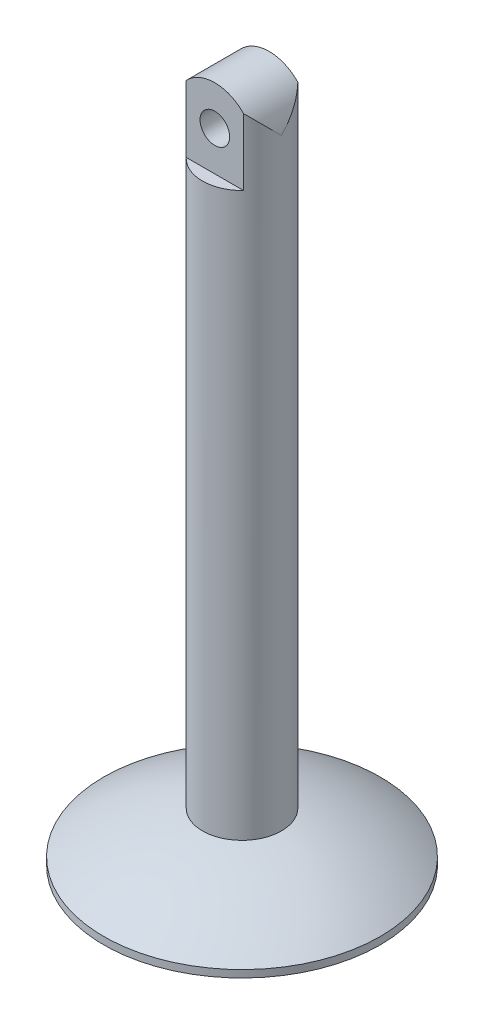
from build123d import *

# Parameters (mm, degrees)
SKETCH1_W               = 4
SKETCH1_H               = 65
CUT_EXTRUDE2_DEPTH      = 15.0000001
CUT_EXTRUDE2_DEPTH_BACK = 15.0000001
SKETCH3_W               = 1.25
SKETCH3_H               = 8
CUT_EXTRUDE3_DEPTH      = 15.0000001
CUT_EXTRUDE3_DEPTH_BACK = 15.0000001


with BuildPart() as part:
    # Sketch1 → Revolve1 (revolve)
    with BuildSketch(Plane.XY):
        with BuildLine():
            ThreePointArc((-4, -65), (-9.225090437, -66.601484736), (-14, -69.259785338))
            Line((-14, -69.259785338), (-14, -70))
            Line((-14, -70), (0, -70))
            Line((0, -70), (0, -65))
            Line((0, -65), (-4, -65))
        make_face()
        with Locations((-2, -32.5)):
            Rectangle(SKETCH1_W, SKETCH1_H)
    revolve(axis=Axis((0, 0, 0), (0, -1, 0)))

    # Sketch2 → Cut-Extrude2 (cut, two sides)
    with BuildSketch(Plane.XY) as cut_extrude2_sk:
        with BuildLine():
            Line((-4, 0), (-4, -4))
            ThreePointArc((-4, -4), (-2.828427125, -1.171572875), (0, 0))
            Line((0, 0), (-4, 0))
        make_face()
        with BuildLine():
            ThreePointArc((0, 0), (2.828427125, -1.171572875), (4, -4))
            Line((4, -4), (4, 0))
            Line((4, 0), (0, 0))
        make_face()
        with BuildLine():
            ThreePointArc((-1.5, -4), (0, -5.5), (1.5, -4))
            Line((1.5, -4), (-1.5, -4))
        make_face()
        with BuildLine():
            Line((-1.5, -4), (1.5, -4))
            ThreePointArc((1.5, -4), (0, -2.5), (-1.5, -4))
        make_face()
    extrude(amount=CUT_EXTRUDE2_DEPTH, mode=Mode.SUBTRACT)
    extrude(cut_extrude2_sk.sketch, amount=-CUT_EXTRUDE2_DEPTH_BACK, mode=Mode.SUBTRACT)

    # Sketch3 → Cut-Extrude3 (cut, two sides)
    with BuildSketch(Plane(origin=(0, 0, 0), x_dir=(0, 0, -1), z_dir=(1, 0, 0))) as cut_extrude3_sk:
        with Locations((-3.375, -4)):
            Rectangle(SKETCH3_W, SKETCH3_H)
        with Locations((3.375, -4)):
            Rectangle(SKETCH3_W, SKETCH3_H)
    extrude(amount=CUT_EXTRUDE3_DEPTH, mode=Mode.SUBTRACT)
    extrude(cut_extrude3_sk.sketch, amount=-CUT_EXTRUDE3_DEPTH_BACK, mode=Mode.SUBTRACT)


solid = part.part
